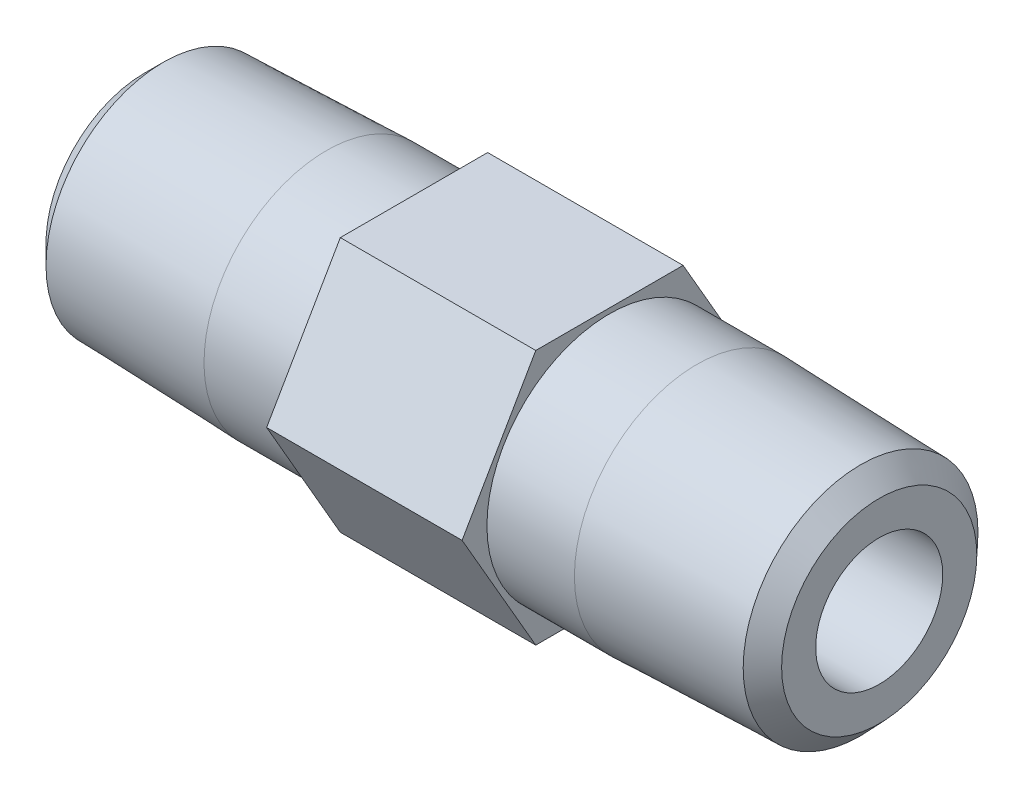
from build123d import *

# Parameters (mm, degrees)
BOSS_EXTRUDE1_DEPTH         = 10.94232
F_1_4_CLEARANCE_HOLE1_D     = 7.112
F_1_4_CLEARANCE_HOLE1_DEPTH = 15.10284
F_1_4_CLEARANCE_HOLE2_D     = 7.112
F_1_4_CLEARANCE_HOLE2_DEPTH = 15.10284
CHAMFER1_SIZE2              = 1.076433961
CHAMFER1_SIZE               = 1.042413957
CHAMFER1_EDGE_2_SIZE2       = 1.042413957
CHAMFER1_EDGE_2_SIZE        = 1.076433961


with BuildPart() as part:
    # Sketch1 → Boss-Extrude1 (new body)
    with BuildSketch(Plane(origin=(15.10284, 0, 0), x_dir=(0, -1, 0), z_dir=(-1, 0, 0))):
        Polygon((7.14375, -4.124445986), (7.14375, 4.124445986), (0, 8.248891971), (-7.14375, 4.124445986), (-7.14375, -4.124445986), (0, -8.248891971), align=None)
    extrude(amount=-BOSS_EXTRUDE1_DEPTH)

    # Sketch2 → Revolve1 (revolve)
    with BuildSketch(Plane(origin=(0, 0, 0), x_dir=(-1, 0, 0), z_dir=(0, 0, -1))):
        Polygon((-41.148, 6.540243957), (-41.148, 0), (-26.04516, 0), (-26.04516, 6.858), (-30.94228, 6.858), align=None)
    revolve(axis=Axis((41.148, 0, 0), (-1, 0, 0)))

    # Sketch3 → Revolve2 (revolve)
    with BuildSketch(Plane(origin=(0, 0, 0), x_dir=(-1, 0, 0), z_dir=(0, 0, -1))):
        Polygon((-15.10284, 6.858), (-15.10284, 0), (0, 0), (0, 6.540243957), (-10.20572, 6.858), align=None)
    revolve(axis=Axis((15.10284, 0, 0), (-1, 0, 0)))

    # 1/4 Clearance Hole1
    with Locations(Plane(origin=(41.148, 0, 0), x_dir=(0, 0, -1), z_dir=(1, 0, 0))):
        with Locations((0, 0)):
            Hole(F_1_4_CLEARANCE_HOLE1_D / 2, depth=F_1_4_CLEARANCE_HOLE1_DEPTH)

    # 1/4 Clearance Hole2
    with Locations(Plane.ZY):
        with Locations((0, 0)):
            Hole(F_1_4_CLEARANCE_HOLE2_D / 2, depth=F_1_4_CLEARANCE_HOLE2_DEPTH)

    # Chamfer1
    chamfer1_edges = [part.edges().sort_by_distance(p)[0] for p in [
        (41.148, -6.540243957, 0),
    ]]
    chamfer(chamfer1_edges, length=CHAMFER1_SIZE, length2=CHAMFER1_SIZE2)

    # Chamfer1 edge 2
    chamfer1_edge_2_edges = [part.edges().sort_by_distance(p)[0] for p in [
        (0, -6.540243957, 0),
    ]]
    chamfer(chamfer1_edge_2_edges, length=CHAMFER1_EDGE_2_SIZE, length2=CHAMFER1_EDGE_2_SIZE2)


solid = part.part
